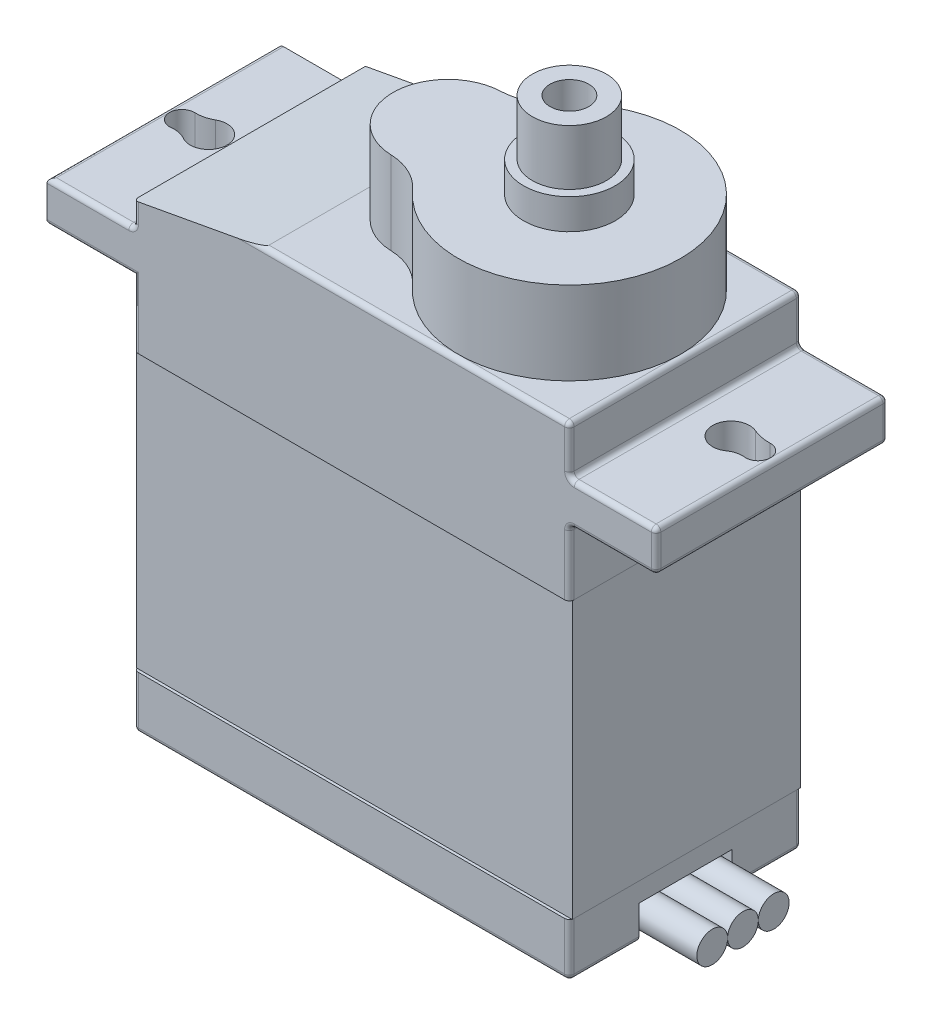
from build123d import *

# Parameters (mm, degrees)
CROQUIS1_W                   = 22.67
CROQUIS1_H                   = 12.06
SALIENTE_EXTRUIR1_DEPTH      = 25.15
CROQUIS2_W                   = 12.06
CROQUIS2_H                   = 2.13
SALIENTE_EXTRUIR2_DEPTH      = 4.51
CROQUIS5_W                   = 12.06
CROQUIS5_H                   = 2.13
SALIENTE_EXTRUIR3_DEPTH      = 4.51
REDONDEO1_R                  = 0.25
CORTAR_EXTRUIR12_DEPTH       = 4.51
SALIENTE_EXTRUIR4_DEPTH      = 4.32
CROQUIS9_R                   = 2.385
SALIENTE_EXTRUIR5_DEPTH      = 1.58
CROQUIS10_R                  = 2.385
SALIENTE_EXTRUIR6_DEPTH      = 2.88
CROQUIS11_R                  = 1.01
CORTAR_EXTRUIR13_DEPTH       = 3.88
CROQUIS12_R                  = 2.385
CROQUIS12_R_2                = 1.925
CORTAR_EXTRUIR14_DEPTH       = 2.88
CORTAR_EXTRUIR15_DEPTH       = 16.88
CROQUIS14_W                  = 22.17
CROQUIS14_H                  = 14.33
CORTAR_EXTRUIR16_DEPTH       = 16.88
CROQUIS16_W                  = 11.56
CROQUIS16_H                  = 14.354716837
CORTAR_EXTRUIR17_DEPTH       = 27.88
CROQUIS17_W                  = 22.67
CROQUIS17_H                  = 14.354716837
CORTAR_EXTRUIR18_DEPTH       = 27.88
CORTAR_EXTRUIR18_DEPTH_BACK  = 27.88
CROQUIS18_W                  = 22.67
CROQUIS18_H                  = 14.354716837
SALIENTE_EXTRUIR7_DEPTH      = 5.88
SALIENTE_EXTRUIR7_DEPTH_BACK = 6
CROQUIS19_W                  = 4.84
CROQUIS19_H                  = 1.754840309
CORTAR_EXTRUIR19_DEPTH       = 1.6
CROQUIS20_R                  = 0.8
SALIENTE_EXTRUIR8_DEPTH      = 4.6
SALIENTE_EXTRUIR8_2_DEPTH    = 4.6
SALIENTE_EXTRUIR8_3_DEPTH    = 4.6


with BuildPart() as part:
    # Croquis1 → Saliente-Extruir1 (new body)
    with BuildSketch(Plane(origin=(0, 0, 0), x_dir=(1, 0, 0), z_dir=(0, 1, 0))):
        Rectangle(CROQUIS1_W, CROQUIS1_H)
    extrude(amount=SALIENTE_EXTRUIR1_DEPTH)

    # Croquis2 → Saliente-Extruir2 (add)
    with BuildSketch(Plane(origin=(11.335, 0, 0), x_dir=(0, 0, -1), z_dir=(1, 0, 0))):
        with Locations((0, 21.595)):
            Rectangle(CROQUIS2_W, CROQUIS2_H)
    extrude(amount=SALIENTE_EXTRUIR2_DEPTH)

    # Croquis5 → Saliente-Extruir3 (add)
    with BuildSketch(Plane.ZY.offset(11.335)):
        with Locations((0, 21.595)):
            Rectangle(CROQUIS5_W, CROQUIS5_H)
    extrude(amount=SALIENTE_EXTRUIR3_DEPTH)

    # Redondeo1
    redondeo1_edges = [part.edges().sort_by_distance(p)[0] for p in [
        (-11.335, 23.905, 6.03),
        (11.335, 10.265, 6.03),
        (11.335, 23.905, 6.03),
        (11.335, 23.905, -6.03),
        (11.335, 10.265, -6.03),
        (11.335, 0, 0),
        (0, 0, -6.03),
        (0, 0, 6.03),
        (-11.335, 0, 0),
        (-11.335, 10.265, -6.03),
        (-11.335, 10.265, 6.03),
        (-13.59, 20.53, 6.03),
        (-13.59, 22.66, 6.03),
        (0, 25.15, -6.03),
        (0, 25.15, 6.03),
        (-11.335, 22.66, 0),
        (-11.335, 25.15, 0),
        (11.335, 25.15, 0),
        (13.59, 20.53, 6.03),
        (13.59, 22.66, 6.03),
        (13.59, 22.66, -6.03),
        (13.59, 20.53, -6.03),
        (11.335, 20.53, 0),
        (11.335, 22.66, 0),
        (15.845, 21.595, -6.03),
        (15.845, 21.595, 6.03),
        (15.845, 20.53, 0),
        (15.845, 22.66, 0),
        (-15.845, 20.53, 0),
        (-15.845, 22.66, 0),
    ]]
    fillet(redondeo1_edges, radius=REDONDEO1_R)

    # Croquis6 → Cortar-Extruir12 (cut)
    with BuildSketch(Plane(origin=(0, 22.66, 0), x_dir=(1, 0, 0), z_dir=(0, 1, 0))):
        with BuildLine():
            ThreePointArc((-14.075367742, -0.703262129), (-12.630008684, 0.120916802), (-14.068304498, 0.957360983))
            ThreePointArc((-14.068304498, 0.957360983), (-14.480150175, 0.792305621), (-14.921605562, 0.74783906))
            ThreePointArc((-14.921605562, 0.74783906), (-15.594396637, 0.072910823), (-14.865906344, -0.541481437))
            ThreePointArc((-14.865906344, -0.541481437), (-14.457242144, -0.556917834), (-14.075367742, -0.703262129))
        make_face()
        with BuildLine():
            ThreePointArc((14.149252725, -0.655279686), (12.635645512, 0.021040815), (13.968135683, 1.007390733))
            ThreePointArc((13.968135683, 1.007390733), (14.44022027, 0.862504591), (14.932312366, 0.821258744))
            ThreePointArc((14.932312366, 0.821258744), (15.594285679, 0.14353072), (14.871650813, -0.469105219))
            ThreePointArc((14.871650813, -0.469105219), (14.493048788, -0.494665037), (14.149252725, -0.655279686))
        make_face()
    extrude(amount=-CORTAR_EXTRUIR12_DEPTH, mode=Mode.SUBTRACT)

    # Croquis13 → Cortar-Extruir15 (cut)
    with BuildSketch(Plane.XY.offset(6.03)):
        Polygon((-4.540532383, 25.15), (-11.335, 23.905), (-11.335, 25.15), align=None)
    extrude(amount=-CORTAR_EXTRUIR15_DEPTH, mode=Mode.SUBTRACT)

    # Croquis14 → Cortar-Extruir16 (cut)
    with BuildSketch(Plane.XY.offset(6.03)):
        with Locations((0, 9.935)):
            Rectangle(CROQUIS14_W, CROQUIS14_H)
    extrude(amount=-CORTAR_EXTRUIR16_DEPTH, mode=Mode.SUBTRACT)

    # Croquis16 → Cortar-Extruir17 (cut)
    with BuildSketch(Plane.ZY.offset(11.335)):
        with Locations((0, 9.932198727)):
            Rectangle(CROQUIS16_W, CROQUIS16_H)
    extrude(amount=-CORTAR_EXTRUIR17_DEPTH, mode=Mode.SUBTRACT)

    # Croquis17 → Cortar-Extruir18 (cut, two sides)
    with BuildSketch(Plane.XY) as cortar_extruir18_sk:
        with Locations((0, 9.932198727)):
            Rectangle(CROQUIS17_W, CROQUIS17_H)
    extrude(amount=CORTAR_EXTRUIR18_DEPTH, mode=Mode.SUBTRACT)
    extrude(cortar_extruir18_sk.sketch, amount=-CORTAR_EXTRUIR18_DEPTH_BACK, mode=Mode.SUBTRACT)

    # Croquis19 → Cortar-Extruir19 (cut)
    with BuildSketch(Plane(origin=(11.335, 0, 0), x_dir=(0, 0, -1), z_dir=(1, 0, 0))):
        with Locations((0, 0.877420155)):
            Rectangle(CROQUIS19_W, CROQUIS19_H)
    extrude(amount=-CORTAR_EXTRUIR19_DEPTH, mode=Mode.SUBTRACT)


with BuildPart() as body_2:
    # Croquis8 → Saliente-Extruir4 (new body)
    with BuildSketch(Plane(origin=(0, 25.15, 0), x_dir=(1, 0, 0), z_dir=(0, 1, 0))):
        with BuildLine():
            ThreePointArc((0.994686763, -3.850921942), (11.085, 0), (0.994686763, 3.850921942))
            ThreePointArc((0.994686763, 3.850921942), (0.038958362, 3.138827688), (-1.119352695, 2.85809561))
            ThreePointArc((-1.119352695, 2.85809561), (-3.875, 0), (-1.119352695, -2.85809561))
            ThreePointArc((-1.119352695, -2.85809561), (0.038958362, -3.138827688), (0.994686763, -3.850921942))
        make_face()
    extrude(amount=SALIENTE_EXTRUIR4_DEPTH)


with BuildPart() as body_3:
    # Croquis9 → Saliente-Extruir5 (new body)
    with BuildSketch(Plane(origin=(0, 29.47, 0), x_dir=(1, 0, 0), z_dir=(0, 1, 0))):
        with Locations((5.305, 0)):
            Circle(CROQUIS9_R)
    extrude(amount=SALIENTE_EXTRUIR5_DEPTH)


with BuildPart() as body_4:
    # Croquis10 → Saliente-Extruir6 (new body)
    with BuildSketch(Plane(origin=(0, 31.05, 0), x_dir=(1, 0, 0), z_dir=(0, 1, 0))):
        with Locations((5.305, 0)):
            Circle(CROQUIS10_R)
    extrude(amount=SALIENTE_EXTRUIR6_DEPTH)


with BuildPart() as cortar_extruir13_tool:
    # Croquis11 → Cortar-Extruir13 (new body)
    with BuildSketch(Plane(origin=(0, 33.93, 0), x_dir=(1, 0, 0), z_dir=(0, 1, 0))):
        with Locations((5.305, 0)):
            Circle(CROQUIS11_R)
    extrude(amount=-CORTAR_EXTRUIR13_DEPTH)


with BuildPart() as body_3_1:
    add(body_3.part)

    # Cortar-Extruir13: cut by cortar_extruir13_tool
    add(cortar_extruir13_tool.part, mode=Mode.SUBTRACT)


with BuildPart() as body_4_1:
    add(body_4.part)

    # Cortar-Extruir13: cut by cortar_extruir13_tool
    add(cortar_extruir13_tool.part, mode=Mode.SUBTRACT)

    # Croquis12 → Cortar-Extruir14 (cut)
    with BuildSketch(Plane(origin=(0, 33.93, 0), x_dir=(1, 0, 0), z_dir=(0, 1, 0))):
        with Locations((5.305, 0)):
            Circle(CROQUIS12_R)
        with Locations((5.305, 0)):
            Circle(CROQUIS12_R_2, mode=Mode.SUBTRACT)
    extrude(amount=-CORTAR_EXTRUIR14_DEPTH, mode=Mode.SUBTRACT)


with BuildPart() as body_5:
    # Croquis18 → Saliente-Extruir7 (new body, two sides)
    with BuildSketch(Plane.XY) as saliente_extruir7_sk:
        with Locations((0, 9.932198727)):
            Rectangle(CROQUIS18_W, CROQUIS18_H)
    extrude(amount=SALIENTE_EXTRUIR7_DEPTH)
    extrude(saliente_extruir7_sk.sketch, amount=-SALIENTE_EXTRUIR7_DEPTH_BACK)


with BuildPart() as body_6:
    # Croquis20 → Saliente-Extruir8 (new body)
    with BuildSketch(Plane(origin=(9.735, 0, 0), x_dir=(0, 0, -1), z_dir=(1, 0, 0))):
        with Locations((-1.6, 0.877420155)):
            Circle(CROQUIS20_R)
    extrude(amount=SALIENTE_EXTRUIR8_DEPTH)


with BuildPart() as body_7:
    # Croquis20 → Saliente-Extruir8 2 (new body)
    with BuildSketch(Plane(origin=(9.735, 0, 0), x_dir=(0, 0, -1), z_dir=(1, 0, 0))):
        with Locations((0, 0.877420155)):
            Circle(CROQUIS20_R)
    extrude(amount=SALIENTE_EXTRUIR8_2_DEPTH)


with BuildPart() as body_8:
    # Croquis20 → Saliente-Extruir8 3 (new body)
    with BuildSketch(Plane(origin=(9.735, 0, 0), x_dir=(0, 0, -1), z_dir=(1, 0, 0))):
        with Locations((1.6, 0.877420155)):
            Circle(CROQUIS20_R)
    extrude(amount=SALIENTE_EXTRUIR8_3_DEPTH)


solid = Compound([part.part, body_2.part, body_3_1.part, body_4_1.part, body_5.part, body_6.part, body_7.part, body_8.part])
